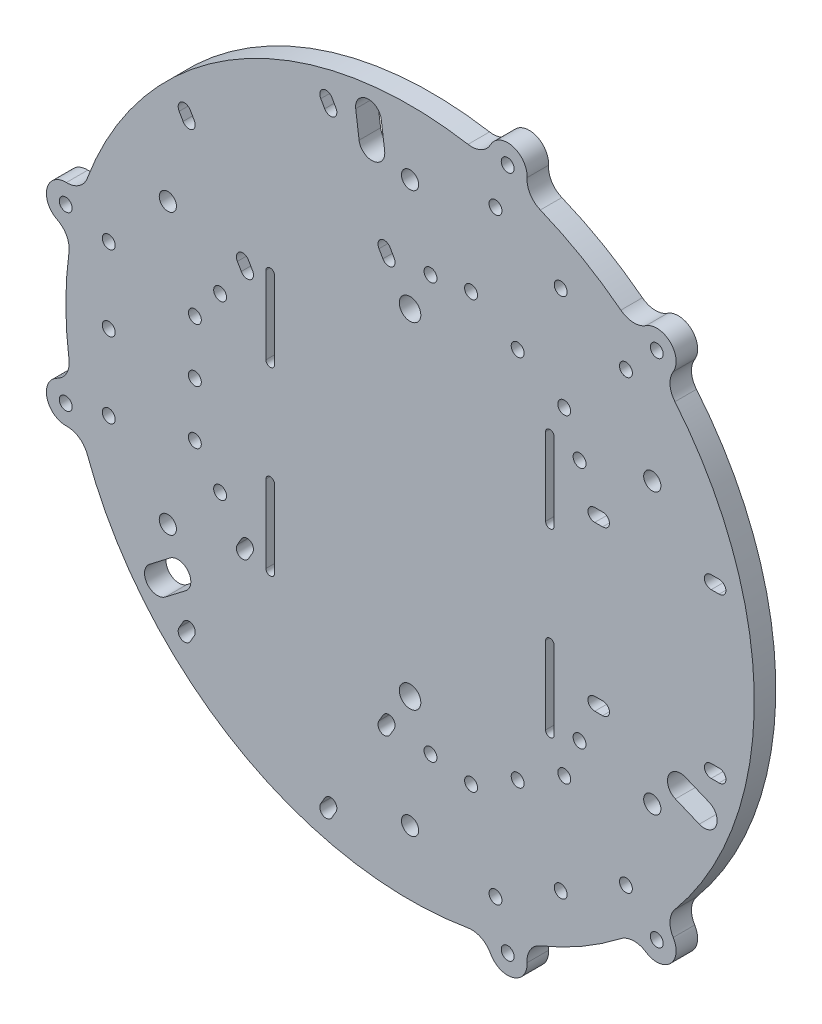
from build123d import *

# Parameters (mm, degrees)
SKETCH1_R                = 80
BOSS_EXTRUDE1_DEPTH      = 5
SKETCH3_R                = 1.5
CUT_EXTRUDE1_DEPTH       = 89.421686036
SKETCH4_RX               = 1.596266659
SKETCH4_RY               = 1.5
CUT_EXTRUDE2_DEPTH       = 6
CIRPATTERN1_COUNT        = 3
SKETCH5_R                = 1.5
CUT_EXTRUDE3_DEPTH       = 6.0000001
CIRPATTERN2_COUNT        = 3
SKETCH6_R                = 4.5
SKETCH6_R_2              = 1.5
BOSS_EXTRUDE2_DEPTH      = 5
FILLET1_R                = 5
CIRPATTERN3_COUNT        = 3
FILLET1_OF_CIRPATTERN3_R = 5
SKETCH7_R                = 2.5
CUT_EXTRUDE4_DEPTH       = 6.0000001
SKETCH8_R                = 2
CUT_EXTRUDE5_DEPTH       = 6.0000001
CUT_EXTRUDE6_DEPTH       = 6.0000001
CIRPATTERN4_COUNT        = 3
SKETCH10_R               = 1.5
CUT_EXTRUDE7_DEPTH       = 6.0000001
CIRPATTERN5_COUNT        = 3


with BuildPart() as part:
    # Sketch1 → Boss-Extrude1 (new body)
    with BuildSketch(Plane.XY):
        Circle(SKETCH1_R)
    extrude(amount=BOSS_EXTRUDE1_DEPTH)

    # Sketch3 → Cut-Extrude1 (cut, through all)
    with BuildSketch(Plane(origin=(19.276806432, 0, -52.96259039), x_dir=(-0.939692621, 0, -0.342020143), z_dir=(0.342020143, 0, -0.939692621))):
        with Locations((-67.479992278, -19)):
            Circle(SKETCH3_R)
        with Locations((-42.05106009, -19)):
            Circle(SKETCH3_R)
        with Locations((-67.479992278, 19)):
            Circle(SKETCH3_R)
        with Locations((-42.05106009, 19)):
            Circle(SKETCH3_R)
    extrude(amount=-CUT_EXTRUDE1_DEPTH, mode=Mode.SUBTRACT)

    # Sketch4 → Cut-Extrude2 (cut, through all)
    with BuildSketch(Plane(origin=(0, 0, 0), x_dir=(-1, 0, 0), z_dir=(0, 0, -1))):
        with Locations(Location((-71.810707869, -19), (0, 0, -180))):
            Ellipse(SKETCH4_RX, SKETCH4_RY)
        with Locations(Location((-69.990856698, -19), (0, 0, -180))):
            Ellipse(SKETCH4_RX, SKETCH4_RY)
        with Locations(Location((-69.990856698, -19), (0, 0, -180))):
            Ellipse(SKETCH4_RX, SKETCH4_RY)
        with Locations(Location((-71.810707869, -19), (0, 0, -180))):
            Ellipse(SKETCH4_RX, SKETCH4_RY)
        with Locations(Location((-71.810707869, -19), (0, 0, -180))):
            Ellipse(SKETCH4_RX, SKETCH4_RY)
        with Locations(Location((-69.990856698, -19), (0, 0, -180))):
            Ellipse(SKETCH4_RX, SKETCH4_RY)
        with BuildLine():
            Line((-69.990856698, -17.5), (-71.810707869, -17.5))
            add(Edge.make_bspline(
                [(-70.900782284, -17.767567899), (-71.311193763, -17.5), (-71.810707869, -17.5)],
                knots=[4.105842265, 4.105842265, 4.105842265, 4.71238898, 4.71238898, 4.71238898], degree=2, weights=[1, 0.954364029, 1]))
            add(Edge.make_bspline(
                [(-69.990856698, -17.5), (-70.490370804, -17.5), (-70.900782284, -17.767567899)],
                knots=[4.71238898, 4.71238898, 4.71238898, 5.318935696, 5.318935696, 5.318935696], degree=2, weights=[1, 0.954364029, 1]))
        make_face()
        with BuildLine():
            Line((-71.810707869, -20.5), (-69.990856698, -20.5))
            add(Edge.make_bspline(
                [(-70.900782284, -20.232432101), (-70.490370804, -20.5), (-69.990856698, -20.5)],
                knots=[0.964249611, 0.964249611, 0.964249611, 1.570796327, 1.570796327, 1.570796327], degree=2, weights=[1, 0.954364029, 1]))
            add(Edge.make_bspline(
                [(-71.810707869, -20.5), (-71.311193763, -20.5), (-70.900782284, -20.232432101)],
                knots=[1.570796327, 1.570796327, 1.570796327, 2.177343042, 2.177343042, 2.177343042], degree=2, weights=[1, 0.954364029, 1]))
        make_face()
        with Locations(Location((-44.749803457, -19), (0, 0, -180))):
            Ellipse(SKETCH4_RX, SKETCH4_RY)
        with Locations(Location((-42.929952286, -19), (0, 0, -180))):
            Ellipse(SKETCH4_RX, SKETCH4_RY)
        with Locations(Location((-44.749803457, -19), (0, 0, -180))):
            Ellipse(SKETCH4_RX, SKETCH4_RY)
        with Locations(Location((-42.929952286, -19), (0, 0, -180))):
            Ellipse(SKETCH4_RX, SKETCH4_RY)
        with Locations(Location((-42.929952286, -19), (0, 0, -180))):
            Ellipse(SKETCH4_RX, SKETCH4_RY)
        with Locations(Location((-44.749803457, -19), (0, 0, -180))):
            Ellipse(SKETCH4_RX, SKETCH4_RY)
        with BuildLine():
            Line((-42.929952286, -17.5), (-44.749803457, -17.5))
            add(Edge.make_bspline(
                [(-43.839877871, -17.767567899), (-44.250289351, -17.5), (-44.749803457, -17.5)],
                knots=[4.105842265, 4.105842265, 4.105842265, 4.71238898, 4.71238898, 4.71238898], degree=2, weights=[1, 0.954364029, 1]))
            add(Edge.make_bspline(
                [(-42.929952286, -17.5), (-43.429466392, -17.5), (-43.839877871, -17.767567899)],
                knots=[4.71238898, 4.71238898, 4.71238898, 5.318935696, 5.318935696, 5.318935696], degree=2, weights=[1, 0.954364029, 1]))
        make_face()
        with BuildLine():
            Line((-44.749803457, -20.5), (-42.929952286, -20.5))
            add(Edge.make_bspline(
                [(-43.839877871, -20.232432101), (-43.429466392, -20.5), (-42.929952286, -20.5)],
                knots=[0.964249611, 0.964249611, 0.964249611, 1.570796327, 1.570796327, 1.570796327], degree=2, weights=[1, 0.954364029, 1]))
            add(Edge.make_bspline(
                [(-44.749803457, -20.5), (-44.250289351, -20.5), (-43.839877871, -20.232432101)],
                knots=[1.570796327, 1.570796327, 1.570796327, 2.177343042, 2.177343042, 2.177343042], degree=2, weights=[1, 0.954364029, 1]))
        make_face()
        with Locations(Location((-44.749803457, 19), (0, 0, -180))):
            Ellipse(SKETCH4_RX, SKETCH4_RY)
        with Locations(Location((-42.929952286, 19), (0, 0, -180))):
            Ellipse(SKETCH4_RX, SKETCH4_RY)
        with Locations(Location((-42.929952286, 19), (0, 0, -180))):
            Ellipse(SKETCH4_RX, SKETCH4_RY)
        with Locations(Location((-44.749803457, 19), (0, 0, -180))):
            Ellipse(SKETCH4_RX, SKETCH4_RY)
        with Locations(Location((-44.749803457, 19), (0, 0, -180))):
            Ellipse(SKETCH4_RX, SKETCH4_RY)
        with Locations(Location((-42.929952286, 19), (0, 0, -180))):
            Ellipse(SKETCH4_RX, SKETCH4_RY)
        with BuildLine():
            Line((-42.929952286, 20.5), (-44.749803457, 20.5))
            add(Edge.make_bspline(
                [(-43.839877871, 20.232432101), (-44.250289351, 20.5), (-44.749803457, 20.5)],
                knots=[4.105842265, 4.105842265, 4.105842265, 4.71238898, 4.71238898, 4.71238898], degree=2, weights=[1, 0.954364029, 1]))
            add(Edge.make_bspline(
                [(-42.929952286, 20.5), (-43.429466392, 20.5), (-43.839877871, 20.232432101)],
                knots=[4.71238898, 4.71238898, 4.71238898, 5.318935696, 5.318935696, 5.318935696], degree=2, weights=[1, 0.954364029, 1]))
        make_face()
        with BuildLine():
            Line((-44.749803457, 17.5), (-42.929952286, 17.5))
            add(Edge.make_bspline(
                [(-43.839877871, 17.767567899), (-43.429466392, 17.5), (-42.929952286, 17.5)],
                knots=[0.964249611, 0.964249611, 0.964249611, 1.570796327, 1.570796327, 1.570796327], degree=2, weights=[1, 0.954364029, 1]))
            add(Edge.make_bspline(
                [(-44.749803457, 17.5), (-44.250289351, 17.5), (-43.839877871, 17.767567899)],
                knots=[1.570796327, 1.570796327, 1.570796327, 2.177343042, 2.177343042, 2.177343042], degree=2, weights=[1, 0.954364029, 1]))
        make_face()
        with Locations(Location((-69.990856698, 19), (0, 0, -180))):
            Ellipse(SKETCH4_RX, SKETCH4_RY)
        with Locations(Location((-71.810707869, 19), (0, 0, -180))):
            Ellipse(SKETCH4_RX, SKETCH4_RY)
        with Locations(Location((-71.810707869, 19), (0, 0, -180))):
            Ellipse(SKETCH4_RX, SKETCH4_RY)
        with Locations(Location((-69.990856698, 19), (0, 0, -180))):
            Ellipse(SKETCH4_RX, SKETCH4_RY)
        with Locations(Location((-71.810707869, 19), (0, 0, -180))):
            Ellipse(SKETCH4_RX, SKETCH4_RY)
        with Locations(Location((-69.990856698, 19), (0, 0, -180))):
            Ellipse(SKETCH4_RX, SKETCH4_RY)
        with BuildLine():
            Line((-69.990856698, 20.5), (-71.810707869, 20.5))
            add(Edge.make_bspline(
                [(-70.900782284, 20.232432101), (-71.311193763, 20.5), (-71.810707869, 20.5)],
                knots=[4.105842265, 4.105842265, 4.105842265, 4.71238898, 4.71238898, 4.71238898], degree=2, weights=[1, 0.954364029, 1]))
            add(Edge.make_bspline(
                [(-69.990856698, 20.5), (-70.490370804, 20.5), (-70.900782284, 20.232432101)],
                knots=[4.71238898, 4.71238898, 4.71238898, 5.318935696, 5.318935696, 5.318935696], degree=2, weights=[1, 0.954364029, 1]))
        make_face()
        with BuildLine():
            Line((-71.810707869, 17.5), (-69.990856698, 17.5))
            add(Edge.make_bspline(
                [(-70.900782284, 17.767567899), (-70.490370804, 17.5), (-69.990856698, 17.5)],
                knots=[0.964249611, 0.964249611, 0.964249611, 1.570796327, 1.570796327, 1.570796327], degree=2, weights=[1, 0.954364029, 1]))
            add(Edge.make_bspline(
                [(-71.810707869, 17.5), (-71.311193763, 17.5), (-70.900782284, 17.767567899)],
                knots=[1.570796327, 1.570796327, 1.570796327, 2.177343042, 2.177343042, 2.177343042], degree=2, weights=[1, 0.954364029, 1]))
        make_face()
    cut_extrude2 = extrude(amount=-CUT_EXTRUDE2_DEPTH, mode=Mode.SUBTRACT)

    # CirPattern1: Cut-Extrude2 ×3 about axis
    cirpattern1_axis = Axis((0, 0, 0), (0, 0, -1))
    for i in range(1, CIRPATTERN1_COUNT):
        add(cut_extrude2.rotate(cirpattern1_axis, i * 360 / CIRPATTERN1_COUNT), mode=Mode.SUBTRACT)

    # Sketch5 → Cut-Extrude3 (cut, through all)
    with BuildSketch(Plane(origin=(0, 0, 0), x_dir=(-1, 0, 0), z_dir=(0, 0, -1))):
        with Locations((44.143493909, 20)):
            Circle(SKETCH5_R)
        with Locations((44.143493909, -20)):
            Circle(SKETCH5_R)
    cut_extrude3 = extrude(amount=-CUT_EXTRUDE3_DEPTH, mode=Mode.SUBTRACT)

    # CirPattern2: Cut-Extrude3 ×3 about axis
    cirpattern2_axis = Axis((0, 0, 0), (0, 0, 1))
    for i in range(1, CIRPATTERN2_COUNT):
        add(cut_extrude3.rotate(cirpattern2_axis, i * 360 / CIRPATTERN2_COUNT), mode=Mode.SUBTRACT)

    # Sketch6 → Boss-Extrude2 (add)
    with BuildSketch(Plane(origin=(0, 0, 0), x_dir=(-1, 0, 0), z_dir=(0, 0, -1))):
        with Locations((80.019782568, -20)):
            Circle(SKETCH6_R)
        with Locations((80.019782568, -20)):
            Circle(SKETCH6_R_2, mode=Mode.SUBTRACT)
        with Locations((80.019782568, 20)):
            Circle(SKETCH6_R)
        with Locations((80.019782568, 20)):
            Circle(SKETCH6_R_2, mode=Mode.SUBTRACT)
    boss_extrude2 = extrude(amount=-BOSS_EXTRUDE2_DEPTH)

    # Fillet1
    fillet1_edges = [part.edges().sort_by_distance(p)[0] for p in [
        (-78.425896412, -15.791731125, 2.5),
        (-76.633395362, -22.963508341, 2.5),
        (-76.633395362, 22.963508341, 2.5),
        (-78.425896412, 15.791731125, 2.5),
    ]]
    fillet(fillet1_edges, radius=FILLET1_R)

    # CirPattern3: Boss-Extrude2 ×3 about axis
    cirpattern3_axis = Axis((0, 0, 0), (0, 0, 1))
    for i in range(1, CIRPATTERN3_COUNT):
        add(boss_extrude2.rotate(cirpattern3_axis, i * 360 / CIRPATTERN3_COUNT))

    # Fillet1 of CirPattern3
    fillet1_of_cirpattern3_edges = [part.edges().sort_by_distance(p)[0] for p in [
        (52.88898853, -60.022953045, 2.5),
        (58.203679264, -54.884712991, 2.5),
        (18.429716098, -77.848221332, 2.5),
        (25.536907882, -75.81468417, 2.5),
        (25.536907882, 75.81468417, 2.5),
        (18.429716098, 77.848221332, 2.5),
        (58.203679264, 54.884712991, 2.5),
        (52.88898853, 60.022953045, 2.5),
    ]]
    fillet(fillet1_of_cirpattern3_edges, radius=FILLET1_OF_CIRPATTERN3_R)

    # Sketch7 → Cut-Extrude4 (cut, through all)
    with BuildSketch(Plane.XY.offset(5)):
        with Locations((0, 39)):
            Circle(SKETCH7_R)
        with Locations((0, -39)):
            Circle(SKETCH7_R)
        with BuildLine():
            Line((-31.5, 30), (-31.5, 12))
            ThreePointArc((-31.5, 12), (-32.5, 11), (-33.5, 12))
            Line((-33.5, 12), (-33.5, 30))
            ThreePointArc((-33.5, 30), (-32.5, 31), (-31.5, 30))
        make_face()
        with BuildLine():
            Line((-31.5, -12), (-31.5, -30))
            ThreePointArc((-31.5, -30), (-32.5, -31), (-33.5, -30))
            Line((-33.5, -30), (-33.5, -12))
            ThreePointArc((-33.5, -12), (-32.5, -11), (-31.5, -12))
        make_face()
        with BuildLine():
            Line((33.5, -12), (33.5, -30))
            ThreePointArc((33.5, -30), (32.5, -31), (31.5, -30))
            Line((31.5, -30), (31.5, -12))
            ThreePointArc((31.5, -12), (32.5, -11), (33.5, -12))
        make_face()
        with BuildLine():
            Line((33.5, 30), (33.5, 12))
            ThreePointArc((33.5, 12), (32.5, 11), (31.5, 12))
            Line((31.5, 12), (31.5, 30))
            ThreePointArc((31.5, 30), (32.5, 31), (33.5, 30))
        make_face()
    extrude(amount=-CUT_EXTRUDE4_DEPTH, mode=Mode.SUBTRACT)

    # Sketch8 → Cut-Extrude5 (cut, through all)
    with BuildSketch(Plane(origin=(0, 0, 0), x_dir=(-1, 0, 0), z_dir=(0, 0, -1))):
        with Locations((0, -65)):
            Circle(SKETCH8_R)
        with Locations((-56.291651246, -32.5)):
            Circle(SKETCH8_R)
        with Locations((-56.291651246, 32.5)):
            Circle(SKETCH8_R)
        with Locations((56.291651246, 32.5)):
            Circle(SKETCH8_R)
        with Locations((56.291651246, -32.5)):
            Circle(SKETCH8_R)
        with Locations((0, 65)):
            Circle(SKETCH8_R)
    extrude(amount=-CUT_EXTRUDE5_DEPTH, mode=Mode.SUBTRACT)

    # Sketch9 → Cut-Extrude6 (cut, through all)
    with BuildSketch(Plane(origin=(0, 0, 0), x_dir=(-1, 0, 0), z_dir=(0, 0, -1))):
        with BuildLine():
            Line((-61.675757914, -28.794111998), (-67.219035109, -31.090212593))
            ThreePointArc((-67.219035109, -31.090212593), (-71.138724003, -29.466624292), (-69.515135703, -25.546935397))
            Line((-69.515135703, -25.546935397), (-63.971858508, -23.250834803))
            ThreePointArc((-63.971858508, -23.250834803), (-60.052169613, -24.874423104), (-61.675757914, -28.794111998))
        make_face()
    cut_extrude6 = extrude(amount=-CUT_EXTRUDE6_DEPTH, mode=Mode.SUBTRACT)

    # CirPattern4: Cut-Extrude6 ×3 about axis
    cirpattern4_axis = Axis((0, 0, 0), (0, 0, 1))
    for i in range(1, CIRPATTERN4_COUNT):
        add(cut_extrude6.rotate(cirpattern4_axis, i * 360 / CIRPATTERN4_COUNT), mode=Mode.SUBTRACT)

    # Sketch10 → Cut-Extrude7 (cut, through all)
    with BuildSketch(Plane(origin=(0, 0, 0), x_dir=(-1, 0, 0), z_dir=(0, 0, -1))):
        with Locations((-19.853210307, -69.386768946)):
            Circle(SKETCH10_R)
        with Locations((-14.180864505, -49.561977818)):
            Circle(SKETCH10_R)
        with Locations((-50.16409944, -51.886768946)):
            Circle(SKETCH10_R)
        with Locations((-35.8314996, -37.061977818)):
            Circle(SKETCH10_R)
        with Locations((-35.008654874, -60.636768946)):
            Circle(SKETCH10_R)
        with Locations((-25.006182053, -43.311977818)):
            Circle(SKETCH10_R)
    cut_extrude7 = extrude(amount=-CUT_EXTRUDE7_DEPTH, mode=Mode.SUBTRACT)

    # CirPattern5: Cut-Extrude7 ×3 about axis
    cirpattern5_axis = Axis((0, 0, 0), (0, 0, 1))
    for i in range(1, CIRPATTERN5_COUNT):
        add(cut_extrude7.rotate(cirpattern5_axis, i * 360 / CIRPATTERN5_COUNT), mode=Mode.SUBTRACT)


solid = part.part
